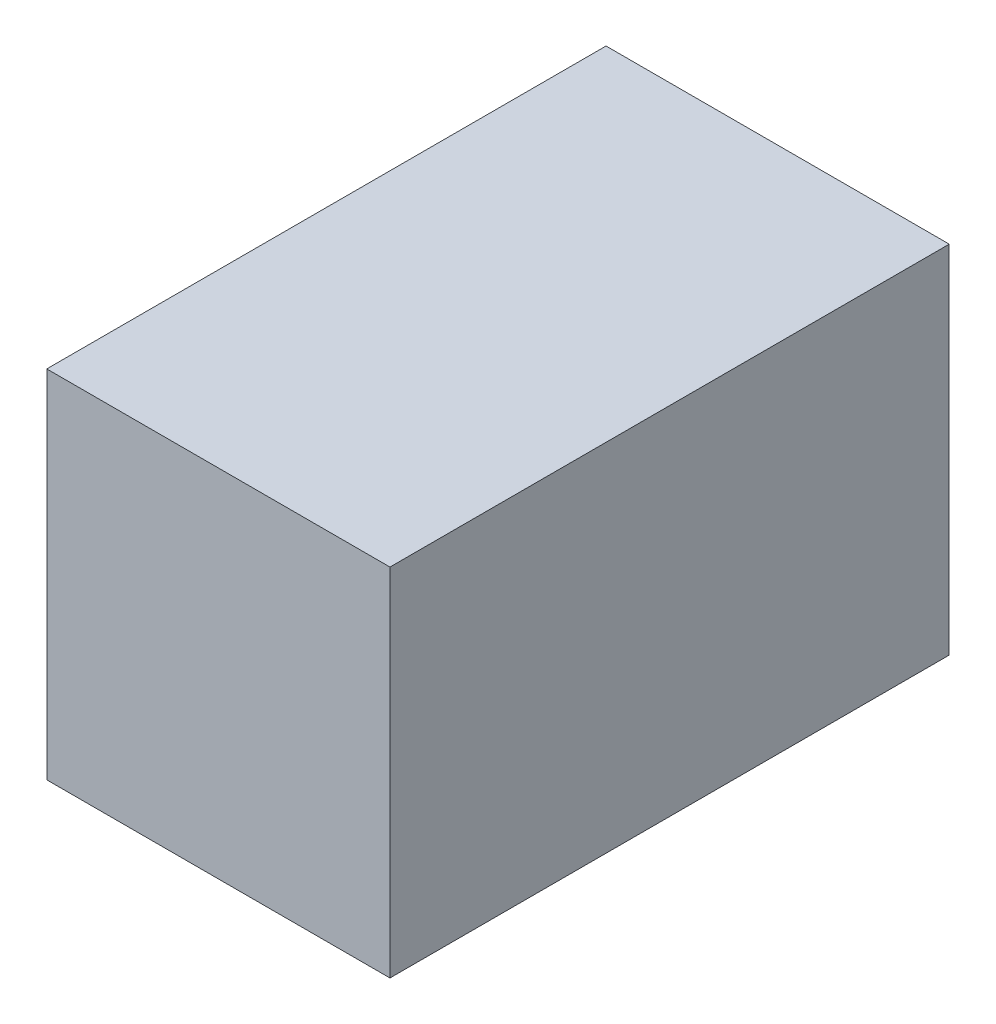
from build123d import *

# Parameters (mm, degrees)
SKETCH1_W           = 171.45
SKETCH1_H           = 279.4
BOSS_EXTRUDE1_DEPTH = 177.8


with BuildPart() as part:
    # Sketch1 → Boss-Extrude1 (new body)
    with BuildSketch(Plane(origin=(0, 0, 0), x_dir=(1, 0, 0), z_dir=(0, 1, 0))):
        with Locations((85.725, 139.7)):
            Rectangle(SKETCH1_W, SKETCH1_H)
    extrude(amount=BOSS_EXTRUDE1_DEPTH)


solid = part.part
